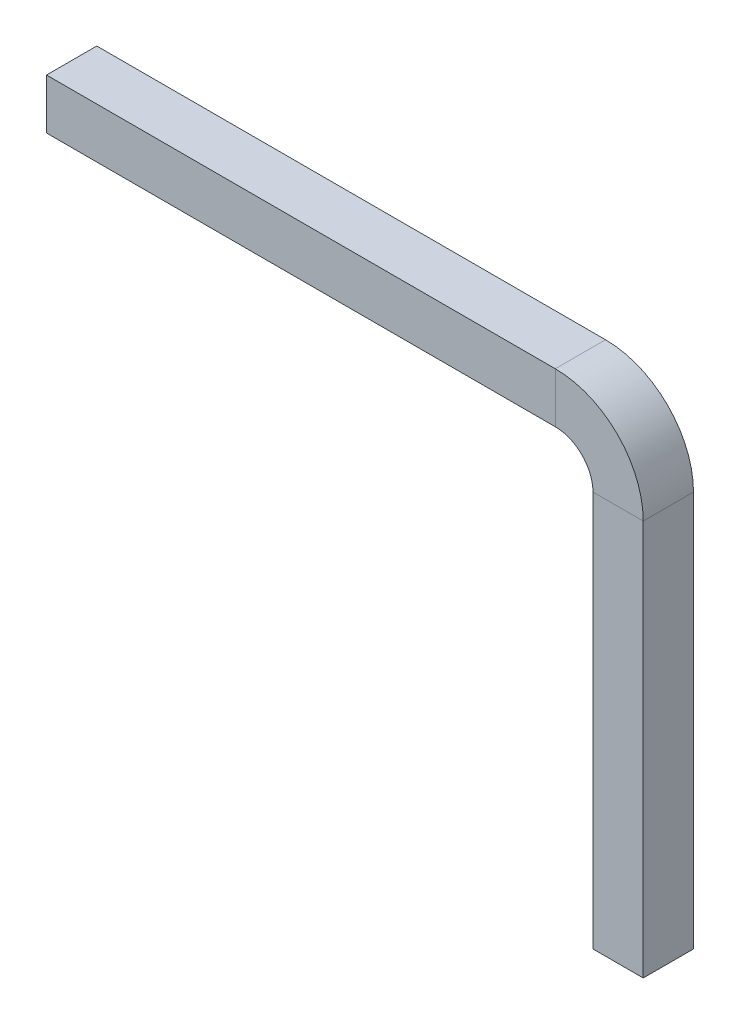
from build123d import *

# Parameters (mm, degrees)
SKETCH2_W     = 0.8
SKETCH2_H     = 0.8
CHAMFER1_SIZE = 0.2


with BuildPart() as part:
    # Sweep1: sweep along a path in Sketch1
    with BuildLine(Plane.XY) as sweep1_path:
        Line((-9.3, 0), (-1, 0))
        ThreePointArc((-1, 0), (-0.292893219, -0.292893219), (0, -1))
        Line((0, -1), (0, -7.5))
    # Sketch2 → Sweep1 (sweep)
    with BuildSketch(Plane(origin=(-9.3, 0, 0), x_dir=(0, 0, -1), z_dir=(1, 0, 0))):
        Rectangle(SKETCH2_W, SKETCH2_H)
    sweep(path=sweep1_path.line)

    # Chamfer1
    chamfer1_edges = [part.edges().sort_by_distance(p)[0] for p in [
        (0, -7.5, 0.4),
        (0.4, -7.5, 0),
        (0, -7.5, -0.4),
        (-0.4, -7.5, 0),
        (-9.3, 0.4, 0),
        (-9.3, 0, -0.4),
        (-9.3, -0.4, 0),
        (-9.3, 0, 0.4),
    ]]
    chamfer(chamfer1_edges, length=CHAMFER1_SIZE)


solid = part.part
